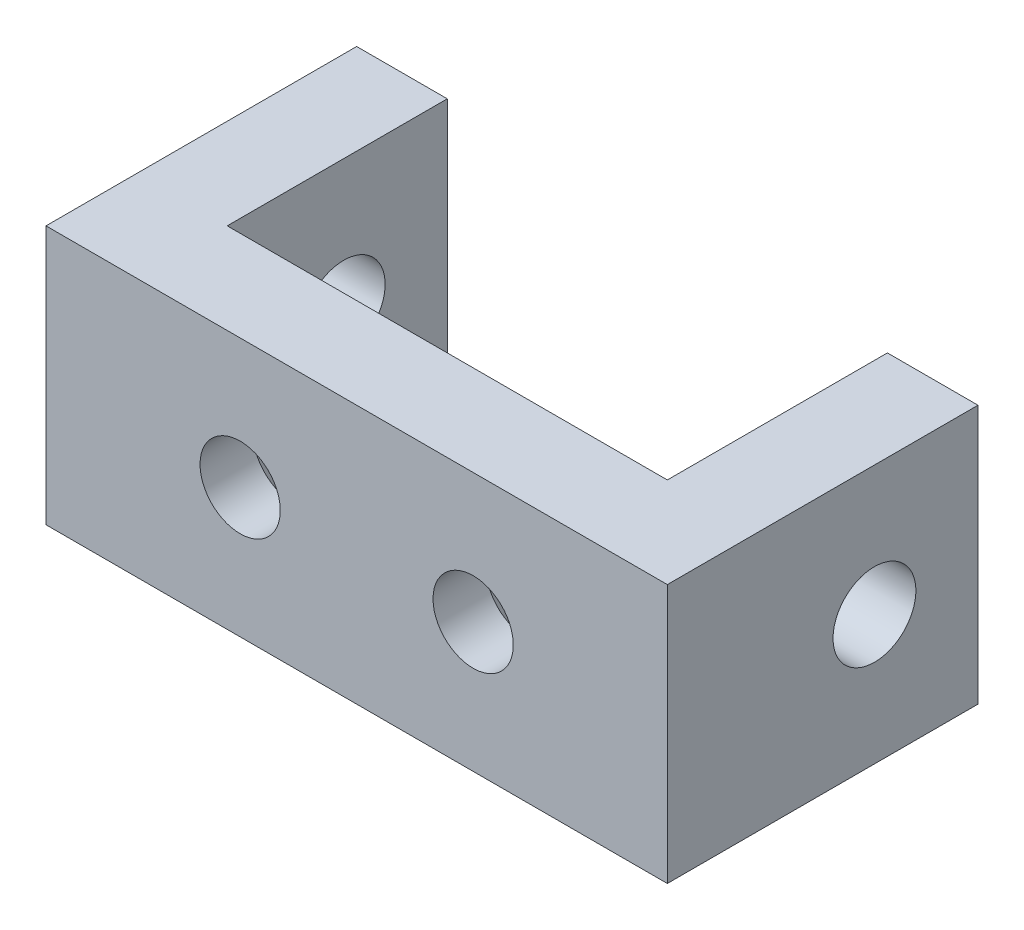
from build123d import *

# Parameters (mm, degrees)
SKETCH1_W                                           = 17
SKETCH1_H                                           = 3.5
BOSS_EXTRUDE1_DEPTH                                 = 10
SKETCH2_R                                           = 1.6
CUT_EXTRUDE1_DEPTH                                  = 25
SKETCH3_R                                           = 1.5
CUT_EXTRUDE2_DEPTH                                  = 4.5
CSK_FOR_M4_COUNTERSUNK_FLAT_HEAD_SCREW1_D           = 3.1
CSK_FOR_M4_COUNTERSUNK_FLAT_HEAD_SCREW1_CSINK_D     = 6
CSK_FOR_M4_COUNTERSUNK_FLAT_HEAD_SCREW1_CSINK_ANGLE = 90


with BuildPart() as part:
    # Sketch1 → Boss-Extrude1 (new body)
    with BuildSketch(Plane(origin=(0, 0, 0), x_dir=(1, 0, 0), z_dir=(0, 1, 0))):
        Polygon((-12, -1.75), (-8.5, -1.75), (-8.5, 1.75), (-8.5, 10.25), (-12, 10.25), align=None)
        Rectangle(SKETCH1_W, SKETCH1_H)
        Polygon((8.5, 1.75), (8.5, -1.75), (12, -1.75), (12, 10.25), (8.5, 10.25), align=None)
    extrude(amount=BOSS_EXTRUDE1_DEPTH)

    # Sketch2 → Cut-Extrude1 (cut, through all)
    with BuildSketch(Plane.ZY.offset(12)):
        with Locations((-6.25, 5)):
            Circle(SKETCH2_R)
    extrude(amount=-CUT_EXTRUDE1_DEPTH, mode=Mode.SUBTRACT)

    # Sketch3 → Cut-Extrude2 (cut, through all)
    with BuildSketch(Plane(origin=(0, 0, -1.75), x_dir=(-1, 0, 0), z_dir=(0, 0, -1))):
        with Locations((-4.5, 5)):
            Circle(SKETCH3_R)
        with Locations((4.5, 5)):
            Circle(SKETCH3_R)
    extrude(amount=-CUT_EXTRUDE2_DEPTH, mode=Mode.SUBTRACT)

    # CSK for M4 Countersunk Flat Head Screw1 (through all)
    with Locations(Plane(origin=(4.5, 5, -1.75), x_dir=(-1, 0, 0), z_dir=(0, 0, -1))):
        with Locations((0, 0), (9, 0)):
            CounterSinkHole(CSK_FOR_M4_COUNTERSUNK_FLAT_HEAD_SCREW1_D / 2, CSK_FOR_M4_COUNTERSUNK_FLAT_HEAD_SCREW1_CSINK_D / 2, counter_sink_angle=CSK_FOR_M4_COUNTERSUNK_FLAT_HEAD_SCREW1_CSINK_ANGLE)


solid = part.part
